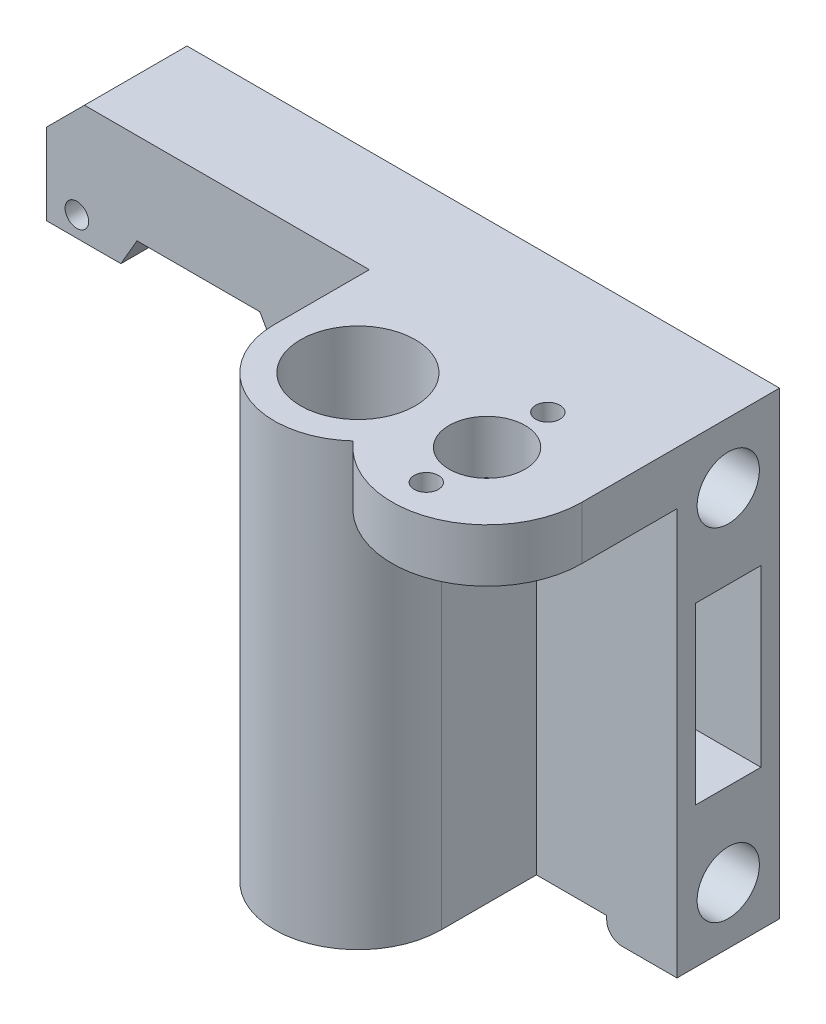
from build123d import *

# Parameters (mm, degrees)
CROQUIS1_R              = 7.55
CROQUIS1_R_2            = 5
SALIENTE_EXTRUIR1_DEPTH = 7
SALIENTE_EXTRUIR2_DEPTH = 51
CROQUIS3_R              = 7.55
SALIENTE_EXTRUIR3_DEPTH = 51
CORTAR_EXTRUIR2_DEPTH   = 14.5
CROQUIS7_R              = 4.1
CORTAR_EXTRUIR3_DEPTH   = 35
CROQUIS8_W              = 8.6
CROQUIS8_H              = 23
CORTAR_EXTRUIR4_DEPTH   = 84
CROQUIS10_R             = 1.55
CORTAR_EXTRUIR7_DEPTH   = 14.5
CORTAR_EXTRUIR8_DEPTH   = 14.5
CROQUIS12_W             = 14.417096231
CROQUIS12_H             = 5
CORTAR_EXTRUIR9_DEPTH   = 14.5
CROQUIS13_W             = 9.25
CROQUIS13_H             = 13.5
SALIENTE_EXTRUIR4_DEPTH = 2.5
REDONDEO2_R             = 2
CROQUIS14_R             = 1
CORTAR_EXTRUIR10_DEPTH  = 4
CROQUIS15_R             = 1.6
CORTAR_EXTRUIR11_DEPTH  = 61.5


with BuildPart() as part:
    # Croquis1 → Saliente-Extruir1 (new body)
    with BuildSketch(Plane(origin=(0, 0, 0), x_dir=(1, 0, 0), z_dir=(0, 1, 0))):
        with BuildLine():
            Line((-11, 0), (-11, 12.5))
            Line((-11, 12.5), (-53.5, 12.5))
            Line((-53.5, 12.5), (-53.5, 26))
            Line((-53.5, 26), (29.5, 26))
            Line((29.5, 26), (29.5, 8))
            Line((29.5, 8), (29.5, 0))
            ThreePointArc((29.5, 0), (21.303512587, -11.735833137), (7.463235294, -8.0808489))
            ThreePointArc((7.463235294, -8.0808489), (-4.410465495, -10.077092543), (-11, 0))
        make_face()
        Circle(CROQUIS1_R, mode=Mode.SUBTRACT)
        with Locations((17, 0)):
            Circle(CROQUIS1_R_2, mode=Mode.SUBTRACT)
    extrude(amount=SALIENTE_EXTRUIR1_DEPTH)

    # Croquis2 → Saliente-Extruir2 (add)
    with BuildSketch(Plane.XZ):
        Polygon((29.5, -26), (29.5, -12.5), (-11, -12.5), (-53.5, -12.5), (-53.5, -26), align=None)
    extrude(amount=SALIENTE_EXTRUIR2_DEPTH)

    # Croquis3 → Saliente-Extruir3 (add)
    with BuildSketch(Plane.XZ):
        with BuildLine():
            Line((-11, 0), (-11, -12.5))
            Line((-11, -12.5), (11, -12.5))
            Line((11, -12.5), (11, 0))
            ThreePointArc((11, 0), (10.077092543, 4.410465495), (7.463235294, 8.0808489))
            ThreePointArc((7.463235294, 8.0808489), (-4.410465495, 10.077092543), (-11, 0))
        make_face()
        Circle(CROQUIS3_R, mode=Mode.SUBTRACT)
    extrude(amount=SALIENTE_EXTRUIR3_DEPTH)

    # Croquis5 → Cortar-Extruir2 (cut, through all)
    with BuildSketch(Plane.XY.offset(-12.5)):
        Polygon((-53.5, 7), (-48.5, 7), (-53.5, 2), align=None)
    extrude(amount=-CORTAR_EXTRUIR2_DEPTH, mode=Mode.SUBTRACT)

    # Croquis7 → Cortar-Extruir3 (cut)
    with BuildSketch(Plane(origin=(29.5, 0, 0), x_dir=(0, 0, -1), z_dir=(1, 0, 0))):
        with Locations((19.25, -1)):
            Circle(CROQUIS7_R)
        with Locations((19.25, -46)):
            Circle(CROQUIS7_R)
    extrude(amount=-CORTAR_EXTRUIR3_DEPTH, mode=Mode.SUBTRACT)

    # Croquis8 → Cortar-Extruir4 (cut, through all)
    with BuildSketch(Plane(origin=(29.5, 0, 0), x_dir=(0, 0, -1), z_dir=(1, 0, 0))):
        with Locations((19.25, -23.5)):
            Rectangle(CROQUIS8_W, CROQUIS8_H)
    extrude(amount=-CORTAR_EXTRUIR4_DEPTH, mode=Mode.SUBTRACT)

    # Croquis10 → Cortar-Extruir7 (cut, through all)
    with BuildSketch(Plane.XY.offset(-12.5)):
        with Locations((-49.5, -6)):
            Circle(CROQUIS10_R)
        with Locations((-18.5, -6)):
            Circle(CROQUIS10_R)
        with Locations((-18.5, -37)):
            Circle(CROQUIS10_R)
    extrude(amount=-CORTAR_EXTRUIR7_DEPTH, mode=Mode.SUBTRACT)

    # Croquis11 → Cortar-Extruir8 (cut, through all)
    with BuildSketch(Plane.XY.offset(-12.5)):
        Polygon((-53.5, -8.669284564), (-53.5, -51), (-25.417096231, -51), (-25.417096231, -33), (-17.334192463, -19), (-25.417096231, -5), (-41.582903769, -5), (-43.7013662, -8.669284564), align=None)
    extrude(amount=-CORTAR_EXTRUIR8_DEPTH, mode=Mode.SUBTRACT)

    # Croquis12 → Cortar-Extruir9 (cut, through all)
    with BuildSketch(Plane.XY.offset(-12.5)):
        with Locations((-18.208548116, -48.5)):
            Rectangle(CROQUIS12_W, CROQUIS12_H)
    extrude(amount=-CORTAR_EXTRUIR9_DEPTH, mode=Mode.SUBTRACT)

    # Croquis13 → Saliente-Extruir4 (add)
    with BuildSketch(Plane.XZ.offset(51)):
        with Locations((24.875, -19.25)):
            Rectangle(CROQUIS13_W, CROQUIS13_H)
    extrude(amount=SALIENTE_EXTRUIR4_DEPTH)

    # Redondeo2
    redondeo2_edges = [part.edges().sort_by_distance(p)[0] for p in [
        (20.25, -53.5, -19.25),
    ]]
    fillet(redondeo2_edges, radius=REDONDEO2_R)

    # Croquis14 → Cortar-Extruir10 (cut)
    with BuildSketch(Plane.XZ.offset(53.5)):
        with Locations((24.25, -14)):
            Circle(CROQUIS14_R)
        with Locations((24.25, -24)):
            Circle(CROQUIS14_R)
    extrude(amount=-CORTAR_EXTRUIR10_DEPTH, mode=Mode.SUBTRACT)

    # Croquis15 → Cortar-Extruir11 (cut, through all)
    with BuildSketch(Plane(origin=(0, 7, 0), x_dir=(1, 0, 0), z_dir=(0, 1, 0))):
        with Locations((17, 8)):
            Circle(CROQUIS15_R)
        with Locations((17, -8)):
            Circle(CROQUIS15_R)
    extrude(amount=-CORTAR_EXTRUIR11_DEPTH, mode=Mode.SUBTRACT)


solid = part.part
